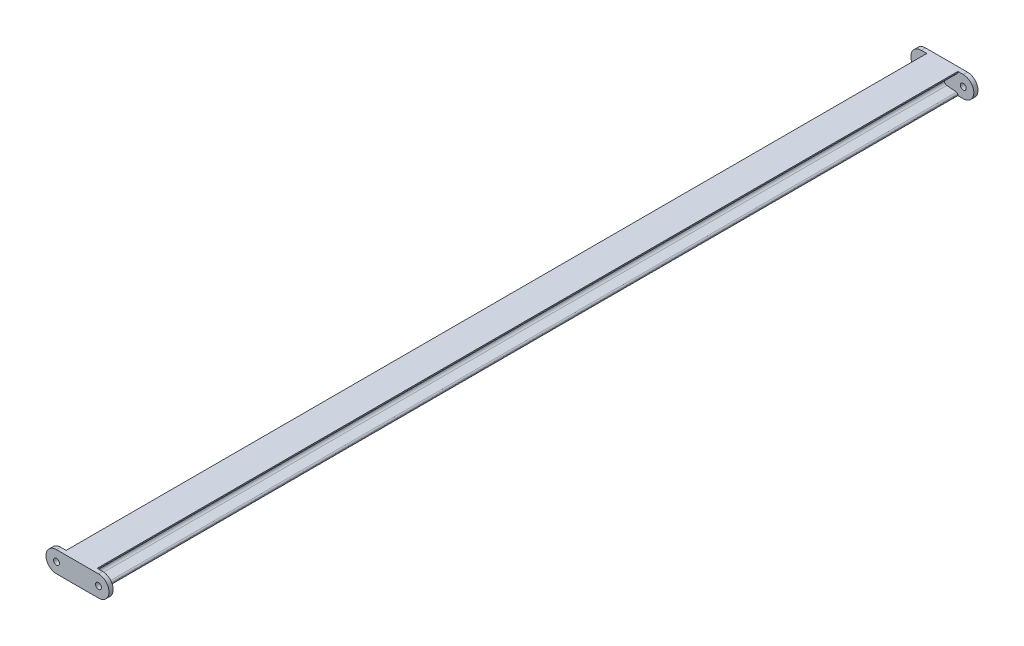
from build123d import *

# Parameters (mm, degrees)
MEMBER_5_1_DEPTH    = 2050
MEMBER_5_2_DEPTH    = 2050
EXTRUDE_1_DEPTH     = 10
SKETCH_14_R         = 7
CUT_EXTRUDE_1_DEPTH = 10


with BuildPart() as part:
    # 草图11 → Member 5_1 (new body)
    with BuildSketch(Plane(origin=(0, 0, 1025), x_dir=(1, 0, 0), z_dir=(0, 0, -1))):
        with BuildLine():
            Line((0, -25), (37, -25))
            Line((37, -25), (37, -22.792319516))
            ThreePointArc((37, -22.792319516), (36.095071711, -20.443787461), (33.848226964, -19.309685745))
            Line((33.848226964, -19.309685745), (10.803546073, -17.005458605))
            ThreePointArc((10.803546073, -17.005458605), (6.309856578, -14.737255173), (4.5, -10.040191063))
            Line((4.5, -10.040191063), (4.5, 10.040191063))
            ThreePointArc((4.5, 10.040191063), (6.309856578, 14.737255173), (10.803546073, 17.005458605))
            Line((10.803546073, 17.005458605), (33.848226964, 19.309685745))
            ThreePointArc((33.848226964, 19.309685745), (36.095071711, 20.443787461), (37, 22.792319516))
            Line((37, 22.792319516), (37, 25))
            Line((37, 25), (0, 25))
            Line((0, 25), (0, -25))
        make_face()
    extrude(amount=MEMBER_5_1_DEPTH)



with BuildPart() as body_2:
    # 草图12 → Member 5_2 (new body)
    with BuildSketch(Plane(origin=(0, 0, 1025), x_dir=(-1, 0, 0), z_dir=(0, 0, -1))):
        with BuildLine():
            Line((0, -25), (37, -25))
            Line((37, -25), (37, -22.792319516))
            ThreePointArc((37, -22.792319516), (36.095071711, -20.443787461), (33.848226964, -19.309685745))
            Line((33.848226964, -19.309685745), (10.803546073, -17.005458605))
            ThreePointArc((10.803546073, -17.005458605), (6.309856578, -14.737255173), (4.5, -10.040191063))
            Line((4.5, -10.040191063), (4.5, 10.040191063))
            ThreePointArc((4.5, 10.040191063), (6.309856578, 14.737255173), (10.803546073, 17.005458605))
            Line((10.803546073, 17.005458605), (33.848226964, 19.309685745))
            ThreePointArc((33.848226964, 19.309685745), (36.095071711, 20.443787461), (37, 22.792319516))
            Line((37, 22.792319516), (37, 25))
            Line((37, 25), (0, 25))
            Line((0, 25), (0, -25))
        make_face()
    extrude(amount=MEMBER_5_2_DEPTH)


with BuildPart() as part_1:
    add(part.part)

    add(body_2.part)  # 凸台-拉伸1 merges body 2
    # 草图13 → 凸台-拉伸1 (add)
    with BuildSketch(Plane.XY.offset(1025)):
        with BuildLine():
            Line((50, -25), (0, -25))
            Line((0, -25), (-50, -25))
            ThreePointArc((-50, -25), (-75, 0), (-50, 25))
            Line((-50, 25), (0, 25))
            Line((0, 25), (50, 25))
            ThreePointArc((50, 25), (75, 0), (50, -25))
        make_face()
    extrude_1 = extrude(amount=EXTRUDE_1_DEPTH)

    # 草图14 → 切除-拉伸1 (cut)
    with BuildSketch(Plane.XY.offset(1035)):
        with Locations((-50, 0)):
            Circle(SKETCH_14_R)
        with Locations((50, 0)):
            Circle(SKETCH_14_R)
    cut_extrude_1 = extrude(amount=-CUT_EXTRUDE_1_DEPTH, mode=Mode.SUBTRACT)

    # 镜向4: 凸台-拉伸1, 切除-拉伸1 across plane
    add(extrude_1.mirror(Plane.XY))
    add(cut_extrude_1.mirror(Plane.XY), mode=Mode.SUBTRACT)


solid = part_1.part
